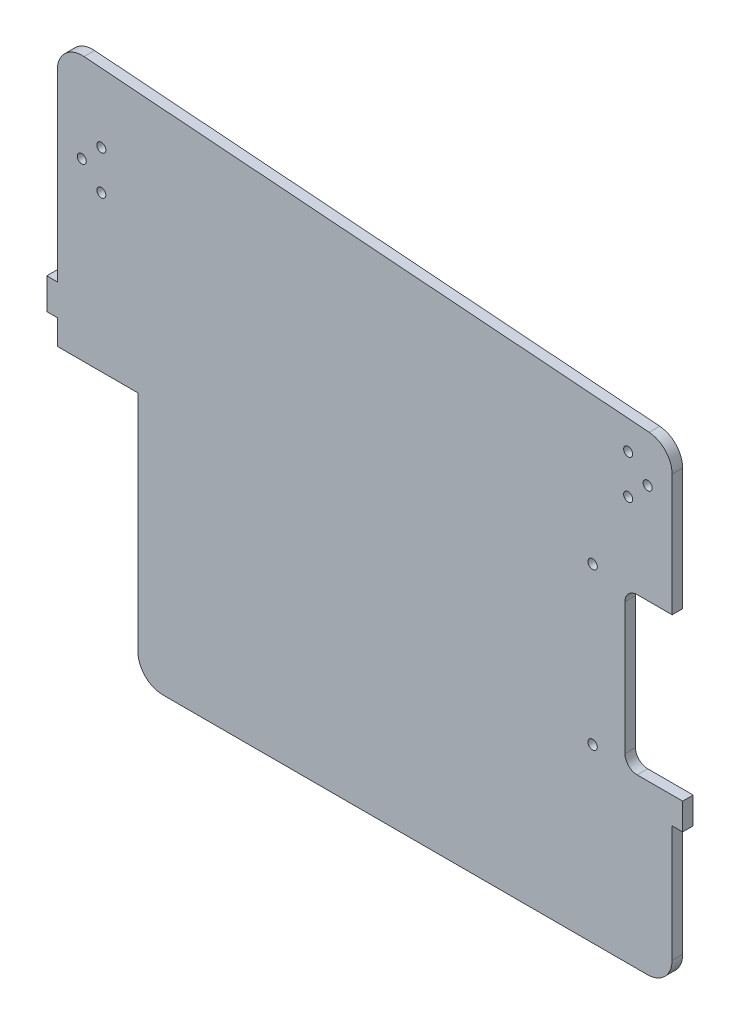
from build123d import *

# Parameters (mm, degrees)
SKETCH4_W                = 4.318
SKETCH4_H                = 191.952333584
BOSS_EXTRUDE1_DEPTH      = 107.682
BOSS_EXTRUDE1_DEPTH_BACK = 144
SKETCH5_R                = 1.905
CUT_EXTRUDE1_DEPTH       = 5.318
SKETCH6_W                = 4.318
SKETCH6_H                = 101.972648506
CUT_EXTRUDE2_DEPTH       = 33
BOSS_EXTRUDE2_DEPTH      = 4.318
SKETCH8_R                = 1.85
CUT_EXTRUDE3_DEPTH       = 5.08
SKETCH9_W                = 4.318
SKETCH9_H                = 10.922
SKETCH9_H_2              = 12.7
BOSS_EXTRUDE3_DEPTH      = 4.318
FILLET2_R                = 10.16


with BuildPart() as part:
    # Sketch4 → Boss-Extrude1 (new body, two sides)
    with BuildSketch(Plane(origin=(0, 0, 0), x_dir=(0, 0, -1), z_dir=(1, 0, 0))) as boss_extrude1_sk:
        with Locations((2.159, -95.976166792)):
            Rectangle(SKETCH4_W, SKETCH4_H)
    extrude(amount=BOSS_EXTRUDE1_DEPTH)
    extrude(boss_extrude1_sk.sketch, amount=-BOSS_EXTRUDE1_DEPTH_BACK)

    # Sketch5 → Cut-Extrude1 (cut, through all)
    with BuildSketch(Plane.XY):
        with Locations((75.14500419, -57.586498411)):
            Circle(SKETCH5_R)
        with Locations((75.14500419, -121.586498411)):
            Circle(SKETCH5_R)
    extrude(amount=-CUT_EXTRUDE1_DEPTH, mode=Mode.SUBTRACT)

    # Sketch6 → Cut-Extrude2 (cut)
    with BuildSketch(Plane.ZY.offset(144)):
        with Locations((-2.159, -140.966009331)):
            Rectangle(SKETCH6_W, SKETCH6_H)
    extrude(amount=-CUT_EXTRUDE2_DEPTH, mode=Mode.SUBTRACT)

    # Sketch7 → Boss-Extrude2 (add)
    with BuildSketch(Plane.XY):
        Polygon((107.682, 0), (-144, 0), (-144, 19.05), align=None)
    extrude(amount=-BOSS_EXTRUDE2_DEPTH)

    # Sketch8 → Cut-Extrude3 (cut)
    with BuildSketch(Plane.XY):
        with Locations((75.14500419, -57.586498411)):
            Circle(SKETCH8_R)
        with Locations((75.14500419, -121.586498411)):
            Circle(SKETCH8_R)
        with Locations((89.682, -10.45)):
            Circle(SKETCH8_R)
        with Locations((97.682, -18.45)):
            Circle(SKETCH8_R)
        with Locations((89.682, -26.45)):
            Circle(SKETCH8_R)
        with Locations((-126, -26.45)):
            Circle(SKETCH8_R)
        with Locations((-126, -10.45)):
            Circle(SKETCH8_R)
        with Locations((-134, -18.45)):
            Circle(SKETCH8_R)
        with BuildLine():
            Line((107.682, -59.311924602), (93.378, -59.311924602))
            ThreePointArc((93.378, -59.311924602), (89.842466094, -60.776390696), (88.378, -64.311924602))
            Line((88.378, -64.311924602), (88.378, -118.206741276))
            ThreePointArc((88.378, -118.206741276), (89.842466094, -121.742275182), (93.378, -123.206741276))
            Line((93.378, -123.206741276), (107.682, -123.206741276))
            Line((107.682, -123.206741276), (107.682, -59.311924602))
        make_face()
    extrude(amount=-CUT_EXTRUDE3_DEPTH, mode=Mode.SUBTRACT)

    # Sketch9 → Boss-Extrude3 (add)
    with BuildSketch(Plane.XY):
        with Locations((109.841, -128.667741276)):
            Rectangle(SKETCH9_W, SKETCH9_H)
        with Locations((-146.159, -73.469685078)):
            Rectangle(SKETCH9_W, SKETCH9_H_2)
    extrude(amount=-BOSS_EXTRUDE3_DEPTH)

    # Fillet2
    fillet2_edges = [part.edges().sort_by_distance(p)[0] for p in [
        (107.682, 0, -2.159),
        (-111, -191.952333584, -2.159),
        (107.682, -191.952333584, -2.159),
        (-144, 19.05, -2.159),
    ]]
    fillet(fillet2_edges, radius=FILLET2_R)


solid = part.part
